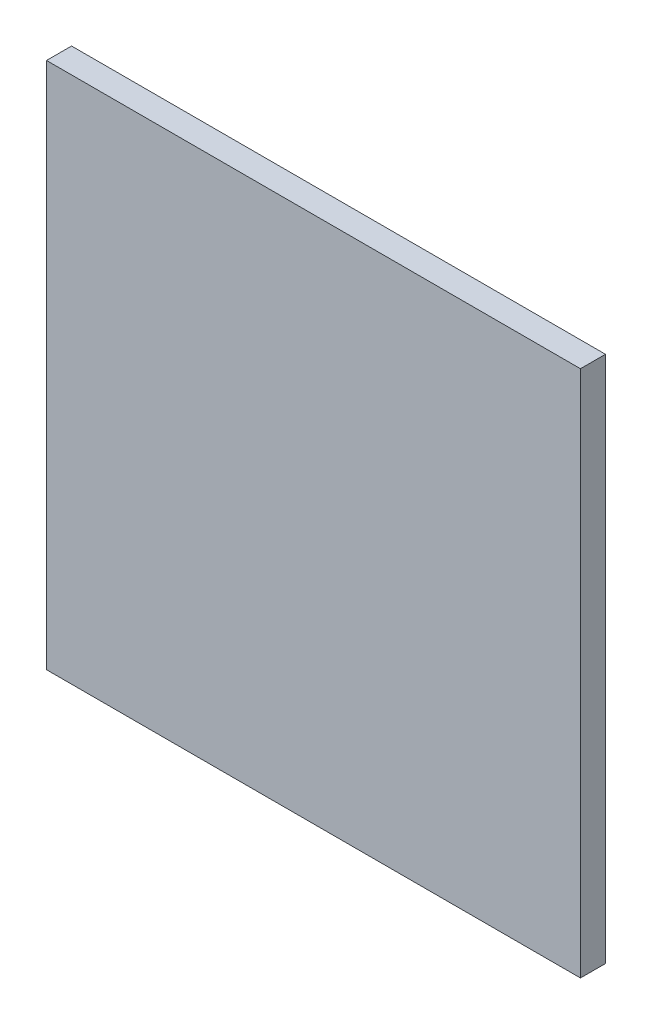
from build123d import *

# Parameters (mm, degrees)
SKETCH1_W           = 64
SKETCH1_H           = 63.25
BOSS_EXTRUDE1_DEPTH = 3


with BuildPart() as part:
    # Sketch1 → Boss-Extrude1 (new body)
    with BuildSketch(Plane.XY):
        Rectangle(SKETCH1_W, SKETCH1_H)
    extrude(amount=BOSS_EXTRUDE1_DEPTH)


solid = part.part
